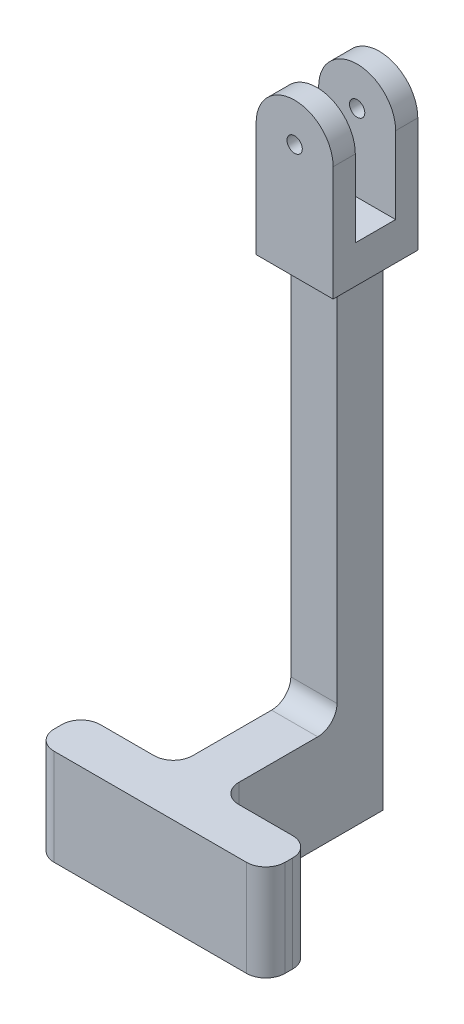
from build123d import *

# Parameters (mm, degrees)
SKETCH_1_R                = 1.985
EXTRUDE_1_DEPTH           = 12
CUT_EXTRUDE_1_DEPTH       = 21
CUT_EXTRUDE_6_DEPTH       = 21
SKETCH_12_R               = 1.985
EXTRUDE_11_DEPTH          = 5
SKETCH_13_R               = 1.985
EXTRUDE_12_DEPTH          = 5
SKETCH_14_W               = 2.04
SKETCH_14_H               = 20
CUT_EXTRUDE_7_DEPTH       = 21
SKETCH_15_W               = 6
SKETCH_15_H               = 6
EXTRUDE_13_DEPTH          = 100
EXTRUDE_14_DEPTH          = 25
EXTRUDE_19_DEPTH          = 7
SKETCH_31_W               = 5
SKETCH_31_H               = 31
EXTRUDE_20_DEPTH          = 45
EXTRUDE_21_DEPTH          = 31
CUT_EXTRUDE_16_DEPTH      = 60
SKETCH_38_W               = 0.2
SKETCH_38_H               = 20
CUT_EXTRUDE_18_DEPTH      = 187
FILLET_2_R                = 10
EXTRUDE_22_DEPTH          = 12
EXTRUDE_23_DEPTH          = 12
SKETCH_46_W               = 12
SKETCH_46_H               = 6
EXTRUDE_24_DEPTH          = 72
SKETCH_45_W               = 12
SKETCH_45_H               = 12
EXTRUDE_26_DEPTH          = 34.5
CUT_EXTRUDE_22_DEPTH      = 56
CUT_EXTRUDE_22_DEPTH_BACK = 183
SKETCH_52_W               = 276.860759989
SKETCH_52_H               = 117.184268482
CUT_EXTRUDE_24_DEPTH      = 26
EXTRUDE_27_DEPTH          = 12
CUT_EXTRUDE_27_DEPTH      = 12
SKETCH_59_W               = 12
SKETCH_59_H               = 29.920197086
EXTRUDE_29_DEPTH          = 25
SKETCH_60_W               = 24
SKETCH_60_H               = 12
EXTRUDE_30_DEPTH          = 12
EXTRUDE_30_DEPTH_BACK     = 25
SKETCH_61_W               = 281.096086155
SKETCH_61_H               = 164.782481761
CUT_EXTRUDE_30_DEPTH      = 50
CUT_EXTRUDE_30_DEPTH_BACK = 58
CUT_EXTRUDE_34_DEPTH      = 25
CUT_EXTRUDE_34_DEPTH_BACK = 37
CUT_EXTRUDE_36_DEPTH      = 26
SKETCH_70_W               = 12
SKETCH_70_H               = 25
CUT_EXTRUDE_37_DEPTH      = 4
SKETCH_71_W               = 24
SKETCH_71_H               = 25
SKETCH_71_W_2             = 12
EXTRUDE_31_DEPTH          = 12
FILLET_3_R                = 5
FILLET_4_R                = 5
CHAMFER_1_SIZE            = 0.5
FILLET_7_R                = 5


with BuildPart() as part:
    # 草圖1 → 填料-伸長1 (new body)
    with BuildSketch(Plane.XY):
        with BuildLine():
            Line((-10, 0), (-10, -30.276417548))
            Line((-10, -30.276417548), (10, -30.276417548))
            Line((10, -30.276417548), (10, 0))
            ThreePointArc((10, 0), (0, 10), (-10, 0))
        make_face()
        Circle(SKETCH_1_R, mode=Mode.SUBTRACT)
    extrude(amount=EXTRUDE_1_DEPTH)

    # 草圖2 → 除料-伸長1 (cut, through all)
    with BuildSketch(Plane(origin=(10, 0, 0), x_dir=(0, 0, -1), z_dir=(1, 0, 0))):
        Polygon((-9, 0), (-6, 0), (-3, 0), (-3, 15.780779257), (-9, 15.780779257), align=None)
        Polygon((-3, 0), (-6, 0), (-9, 0), (-8.60053373, -20), (-3, -20), align=None)
    extrude(amount=-CUT_EXTRUDE_1_DEPTH, mode=Mode.SUBTRACT)

    # 草圖11 → 除料-伸長6 (cut, through all)
    with BuildSketch(Plane(origin=(10, 0, 0), x_dir=(0, 0, -1), z_dir=(1, 0, 0))):
        Polygon((-9, 0), (-9, -20), (-8.60053373, -20), align=None)
    extrude(amount=-CUT_EXTRUDE_6_DEPTH, mode=Mode.SUBTRACT)

    # 草圖12 → 填料-伸長11 (add)
    with BuildSketch(Plane.XY.offset(12)):
        with BuildLine():
            ThreePointArc((10, 0), (0, 10), (-10, 0))
            ThreePointArc((-10, 0), (0, -10), (10, 0))
        make_face()
        Circle(SKETCH_12_R, mode=Mode.SUBTRACT)
        with BuildLine():
            ThreePointArc((10, 0), (0, -10), (-10, 0))
            Line((-10, 0), (-10, -30.276417548))
            Line((-10, -30.276417548), (10, -30.276417548))
            Line((10, -30.276417548), (10, 0))
        make_face()
    extrude(amount=EXTRUDE_11_DEPTH)

    # 草圖13 → 填料-伸長12 (add)
    with BuildSketch(Plane(origin=(0, 0, 0), x_dir=(-1, 0, 0), z_dir=(0, 0, -1))):
        with BuildLine():
            ThreePointArc((10, 0), (0, 10), (-10, 0))
            ThreePointArc((-10, 0), (0, -10), (10, 0))
        make_face()
        Circle(SKETCH_13_R, mode=Mode.SUBTRACT)
        with BuildLine():
            ThreePointArc((10, 0), (0, -10), (-10, 0))
            Line((-10, 0), (-10, -30.276417548))
            Line((-10, -30.276417548), (10, -30.276417548))
            Line((10, -30.276417548), (10, 0))
        make_face()
    extrude(amount=EXTRUDE_12_DEPTH)

    # 草圖14 → 除料-伸長7 (cut, through all)
    with BuildSketch(Plane.ZY.offset(10)):
        Polygon((3, 0), (3, -20), (9, -20), (9, 0), (11.04, 0), (11.04, 10), (3, 10), (0.96, 10), (0.96, 0), align=None)
        with Locations((1.98, -10)):
            Rectangle(SKETCH_14_W, SKETCH_14_H)
        with Locations((10.02, -10)):
            Rectangle(SKETCH_14_W, SKETCH_14_H)
    extrude(amount=-CUT_EXTRUDE_7_DEPTH, mode=Mode.SUBTRACT)

    # 草圖15 → 填料-伸長13 (add)
    with BuildSketch(Plane.XZ.offset(30.276417548)):
        with Locations((3, 9)):
            Rectangle(SKETCH_15_W, SKETCH_15_H)
        with Locations((-3, 9)):
            Rectangle(SKETCH_15_W, SKETCH_15_H)
        with Locations((3, 3)):
            Rectangle(SKETCH_15_W, SKETCH_15_H)
        with Locations((-3, 3)):
            Rectangle(SKETCH_15_W, SKETCH_15_H)
    extrude(amount=EXTRUDE_13_DEPTH)

    # 草圖16 → 填料-伸長14 (add)
    with BuildSketch(Plane.XZ.offset(130.276417548)):
        Polygon((176, -54), (176, 6), (176, 96), (-61, 96), (-61, 6), (-61, -54), align=None)
    extrude(amount=EXTRUDE_14_DEPTH)

    # 草圖30 → 填料-伸長19 (add)
    with BuildSketch(Plane(origin=(0, -130.276417548, 0), x_dir=(1, 0, 0), z_dir=(0, 1, 0))):
        Polygon((119, -68), (139, -68), (139, -37), (129, -37), (119, -37), align=None)
    extrude(amount=EXTRUDE_19_DEPTH)

    # 草圖31 → 填料-伸長20 (add)
    with BuildSketch(Plane(origin=(0, -130.276417548, 0), x_dir=(1, 0, 0), z_dir=(0, 1, 0))):
        Polygon((119, -68), (114, -68), (114, -37.129725066), (119, -37), align=None)
        with Locations((141.5, -52.5)):
            Rectangle(SKETCH_31_W, SKETCH_31_H)
    extrude(amount=EXTRUDE_20_DEPTH)

    # 草圖33 → 填料-伸長21 (add)
    with BuildSketch(Plane.XY.offset(68)):
        Polygon((159, -130.276417548), (144, -130.276417548), (144, -85.276417548), align=None)
        Polygon((114, -85.276417548), (99, -130.276417548), (114, -130.276417548), align=None)
    extrude(amount=-EXTRUDE_21_DEPTH)

    # 草圖35 → 除料-伸長16 (cut, through all)
    with BuildSketch(Plane(origin=(0, 0, 37), x_dir=(-1, 0, 0), z_dir=(0, 0, -1))):
        with BuildLine():
            ThreePointArc((-132.95, -126.776417548), (-134.95, -124.776417548), (-136.95, -126.776417548))
            Line((-136.95, -126.776417548), (-132.95, -126.776417548))
        make_face()
        with BuildLine():
            Line((-132.95, -126.776417548), (-136.95, -126.776417548))
            ThreePointArc((-136.95, -126.776417548), (-134.95, -128.776417548), (-132.95, -126.776417548))
        make_face()
        with BuildLine():
            ThreePointArc((-121.05, -126.776417548), (-123.05, -124.776417548), (-125.05, -126.776417548))
            Line((-125.05, -126.776417548), (-121.05, -126.776417548))
        make_face()
        with BuildLine():
            Line((-121.05, -126.776417548), (-125.05, -126.776417548))
            ThreePointArc((-125.05, -126.776417548), (-123.05, -128.776417548), (-121.05, -126.776417548))
        make_face()
    extrude(amount=-CUT_EXTRUDE_16_DEPTH, mode=Mode.SUBTRACT)

    # 草圖38 → 除料-伸長18 (cut, through all)
    with BuildSketch(Plane.ZY.offset(10)):
        Polygon((11.04, 10), (0.96, 10), (0.76, 10), (0.76, 0), (0.96, 0), (0.96, -20), (11.04, -20), (11.04, 0), (11.24, 0), (11.24, 10), align=None)
        with Locations((0.86, -10)):
            Rectangle(SKETCH_38_W, SKETCH_38_H)
        with Locations((11.14, -10)):
            Rectangle(SKETCH_38_W, SKETCH_38_H)
    extrude(amount=-CUT_EXTRUDE_18_DEPTH, mode=Mode.SUBTRACT)

    # 圓角2
    fillet_2_edges = [part.edges().sort_by_distance(p)[0] for p in [
        (-61, -142.776417548, 96),
        (-61, -142.776417548, -54),
        (176, -142.776417548, -54),
        (176, -142.776417548, 96),
    ]]
    fillet(fillet_2_edges, radius=FILLET_2_R)

    # 草圖39 → 填料-伸長22 (add)
    with BuildSketch(Plane(origin=(0, 0, 0), x_dir=(-1, 0, 0), z_dir=(0, 0, -1))):
        Polygon((-6, -80.276417548), (-16, -130.276417548), (-6, -130.276417548), align=None)
        Polygon((6, -80.276417548), (16, -130.276417548), (6, -130.276417548), align=None)
    extrude(amount=-EXTRUDE_22_DEPTH)

    # 草圖40 → 填料-伸長23 (add)
    with BuildSketch(Plane(origin=(6, 0, 0), x_dir=(0, 0, -1), z_dir=(1, 0, 0))):
        Polygon((-12, -80.276417548), (-22, -130.276417548), (-12, -130.276417548), align=None)
        Polygon((0, -80.276417548), (11.303196885, -130.276417548), (0, -130.276417548), align=None)
    extrude(amount=-EXTRUDE_23_DEPTH)

    # 草圖46 → 填料-伸長24 (add)
    with BuildSketch(Plane(origin=(0, -130.276417548, 0), x_dir=(1, 0, 0), z_dir=(0, 1, 0))):
        with Locations((0, -55.5)):
            Rectangle(SKETCH_46_W, SKETCH_46_H)
        with Locations((0, -49.5)):
            Rectangle(SKETCH_46_W, SKETCH_46_H)
    extrude(amount=EXTRUDE_24_DEPTH)

    # 草圖45 → 填料-伸長26 (add)
    with BuildSketch(Plane.XY.offset(12)):
        with Locations((0, -64.276417548)):
            Rectangle(SKETCH_45_W, SKETCH_45_H)
    extrude(amount=EXTRUDE_26_DEPTH)

    # 草圖50 → 除料-伸長22 (cut, two sides)
    with BuildSketch(Plane.ZY.offset(6)) as cut_extrude_22_sk:
        Polygon((12, -70.276417548), (0, -70.276417548), (-67.39172142, -119.054967007), (-58.508131327, -164.361276479), (22, -164.361276479), (22, -130.276417548), (21.222089752, -86.407773417), align=None)
    extrude(amount=CUT_EXTRUDE_22_DEPTH, mode=Mode.SUBTRACT)
    extrude(cut_extrude_22_sk.sketch, amount=-CUT_EXTRUDE_22_DEPTH_BACK, mode=Mode.SUBTRACT)

    # 草圖52 → 除料-伸長24 (cut, through all)
    with BuildSketch(Plane(origin=(0, -130.276417548, 0), x_dir=(1, 0, 0), z_dir=(0, 1, 0))):
        with Locations((58.121400767, -52.5)):
            Rectangle(SKETCH_52_W, SKETCH_52_H)
        with BuildLine():
            Line((-17.31105843, -29.920197086), (148.30684395, -29.920197086))
            ThreePointArc((148.30684395, -29.920197086), (170.886646864, -52.5), (148.30684395, -75.079802914))
            Line((148.30684395, -75.079802914), (-17.31105843, -75.079802914))
            ThreePointArc((-17.31105843, -75.079802914), (-39.890861345, -52.5), (-17.31105843, -29.920197086))
        make_face(mode=Mode.SUBTRACT)
    extrude(amount=-CUT_EXTRUDE_24_DEPTH, mode=Mode.SUBTRACT)

    # 草圖57 → 填料-伸長27 (add)
    with BuildSketch(Plane.ZY.offset(6)):
        Polygon((12, -70.276417548), (0, -70.276417548), (0, -130.276417548), (46.5, -130.276417548), (46.5, -118.276417548), (45.651807849, -118.276417548), (12, -118.276417548), align=None)
    extrude(amount=-EXTRUDE_27_DEPTH)

    # 草圖58 → 除料-伸長27 (cut)
    with BuildSketch(Plane.ZY.offset(6)):
        Polygon((12, -50.353469845), (12, -118.276417548), (97.717444729, -118.276417548), (103.225359423, -26.791834768), align=None)
    extrude(amount=-CUT_EXTRUDE_27_DEPTH, mode=Mode.SUBTRACT)

    # 草圖59 → 填料-伸長29 (add)
    with BuildSketch(Plane.XZ.offset(130.276417548)):
        with Locations((0, 14.960098543)):
            Rectangle(SKETCH_59_W, SKETCH_59_H)
    extrude(amount=EXTRUDE_29_DEPTH)

    # 草圖60 → 填料-伸長30 (add, two sides)
    with BuildSketch(Plane(origin=(0, -130.276417548, 0), x_dir=(1, 0, 0), z_dir=(0, 1, 0))) as extrude_30_sk:
        with Locations((18, -52.5)):
            Rectangle(SKETCH_60_W, SKETCH_60_H)
        with Locations((-18, -52.5)):
            Rectangle(SKETCH_60_W, SKETCH_60_H)
    extrude(amount=EXTRUDE_30_DEPTH)
    extrude(extrude_30_sk.sketch, amount=-EXTRUDE_30_DEPTH_BACK)

    # 草圖61 → 除料-伸長30 (cut, two sides)
    with BuildSketch(Plane(origin=(0, -130.276417548, 0), x_dir=(1, 0, 0), z_dir=(0, 1, 0))) as cut_extrude_30_sk:
        with Locations((53.510433176, -39.675707669)):
            Rectangle(SKETCH_61_W, SKETCH_61_H)
        Polygon((6, -29.920197086), (6, -46.5), (30, -46.5), (30, -58.5), (-30, -58.5), (-30, -46.5), (-6, -46.5), (-6, -29.920197086), (-44.589128485, 5.230499952), (-9.133666374, 30.61836171), (-3.443283566, 30.61836171), (36.57596573, 16.820537818), align=None, mode=Mode.SUBTRACT)
    extrude(amount=CUT_EXTRUDE_30_DEPTH, mode=Mode.SUBTRACT)
    extrude(cut_extrude_30_sk.sketch, amount=-CUT_EXTRUDE_30_DEPTH_BACK, mode=Mode.SUBTRACT)

    # 草圖64 → 除料-伸長34 (cut, two sides)
    with BuildSketch(Plane.ZY.offset(6)) as cut_extrude_34_sk:
        Polygon((12, -130.276417548), (58.5, -130.276417548), (58.5, -118.447183966), (58.5, -114.238678803), (12, -115.089037544), align=None)
    extrude(amount=CUT_EXTRUDE_34_DEPTH, mode=Mode.SUBTRACT)
    extrude(cut_extrude_34_sk.sketch, amount=-CUT_EXTRUDE_34_DEPTH_BACK, mode=Mode.SUBTRACT)

    # 草圖69 → 除料-伸長36 (cut, through all)
    with BuildSketch(Plane(origin=(0, -130.276417548, 0), x_dir=(1, 0, 0), z_dir=(0, 1, 0))):
        Polygon((-6, -46.5), (6, -46.5), (66.848936529, -34.461710071), (66.848936529, -79.240565932), (-96.240370082, -76.176749478), (-86.106207966, -40.480855035), (-50.518801466, -30.455180862), align=None)
    extrude(amount=-CUT_EXTRUDE_36_DEPTH, mode=Mode.SUBTRACT)

    # 草圖70 → 除料-伸長37 (cut)
    with BuildSketch(Plane.XY.offset(46.5)):
        with Locations((0, -142.776417548)):
            Rectangle(SKETCH_70_W, SKETCH_70_H)
    extrude(amount=-CUT_EXTRUDE_37_DEPTH, mode=Mode.SUBTRACT)

    # 草圖71 → 填料-伸長31 (add)
    with BuildSketch(Plane.XY.offset(42.5)):
        with Locations((-18, -142.776417548)):
            Rectangle(SKETCH_71_W, SKETCH_71_H)
        with Locations((0, -142.776417548)):
            Rectangle(SKETCH_71_W_2, SKETCH_71_H)
        with Locations((18, -142.776417548)):
            Rectangle(SKETCH_71_W, SKETCH_71_H)
    extrude(amount=EXTRUDE_31_DEPTH)

    # 圓角3
    fillet_3_edges = [part.edges().sort_by_distance(p)[0] for p in [
        (30, -142.776417548, 42.5),
        (-30, -142.776417548, 42.5),
        (-30, -142.776417548, 54.5),
        (30, -142.776417548, 54.5),
    ]]
    fillet(fillet_3_edges, radius=FILLET_3_R)

    # 圓角4
    fillet_4_edges = [part.edges().sort_by_distance(p)[0] for p in [
        (0, -130.276417548, 12),
    ]]
    fillet(fillet_4_edges, radius=FILLET_4_R)

    # 導角1
    chamfer_1_edges = [part.edges().sort_by_distance(p)[0] for p in [
        (10, -30.276417548, 6),
        (-10, -30.276417548, 6),
        (0, -30.276417548, 17),
        (0, -30.276417548, -5),
    ]]
    chamfer(chamfer_1_edges, length=CHAMFER_1_SIZE)

    # 圓角7
    fillet_7_edges = [part.edges().sort_by_distance(p)[0] for p in [
        (6, -142.776417548, 42.5),
        (-6, -142.776417548, 42.5),
    ]]
    fillet(fillet_7_edges, radius=FILLET_7_R)


solid = part.part
